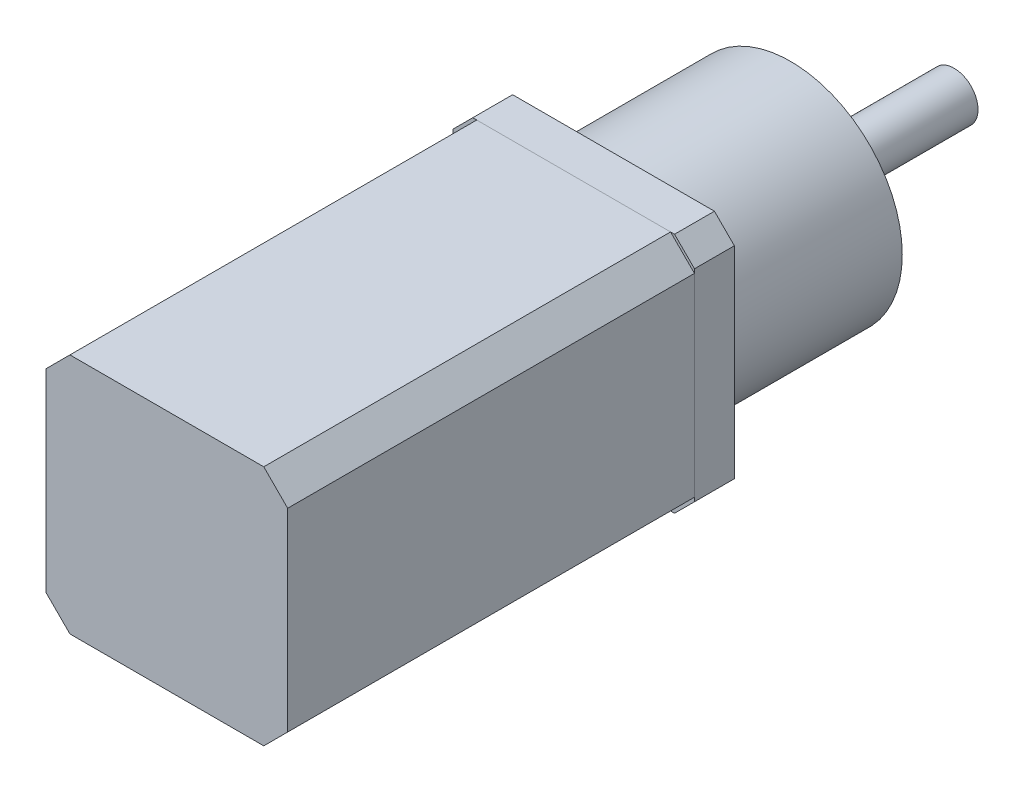
from build123d import *

# Parameters (mm, degrees)
SKETCH1_W           = 30.3
SKETCH1_H           = 30.3
BOSS_EXTRUDE1_DEPTH = 51
SKETCH4_W           = 30.3
SKETCH4_H           = 30.3
BOSS_EXTRUDE4_DEPTH = 5
SKETCH5_R           = 14
BOSS_EXTRUDE5_DEPTH = 22.2
SKETCH6_R           = 9
BOSS_EXTRUDE6_DEPTH = 2
SKETCH7_R           = 3
BOSS_EXTRUDE7_DEPTH = 18.5
SKETCH8_R           = 4.32234312
BOSS_EXTRUDE8_DEPTH = 0.4
CHAMFER1_SIZE       = 3
CHAMFER2_SIZE       = 2.5


with BuildPart() as part:
    # Sketch1 → Boss-Extrude1 (new body)
    with BuildSketch(Plane.XY):
        Rectangle(SKETCH1_W, SKETCH1_H)
    extrude(amount=BOSS_EXTRUDE1_DEPTH)

    # Chamfer1
    chamfer1_edges = [part.edges().sort_by_distance(p)[0] for p in [
        (15.15, -15.15, 25.5),
        (-15.15, -15.15, 25.5),
        (-15.15, 15.15, 25.5),
        (15.15, 15.15, 25.5),
    ]]
    chamfer(chamfer1_edges, length=CHAMFER1_SIZE)


with BuildPart() as body_2:
    # Sketch4 → Boss-Extrude4 (new body)
    with BuildSketch(Plane(origin=(0, 0, 0), x_dir=(-1, 0, 0), z_dir=(0, 0, -1))):
        Rectangle(SKETCH4_W, SKETCH4_H)
    extrude(amount=BOSS_EXTRUDE4_DEPTH)

    # Sketch5 → Boss-Extrude5 (add)
    with BuildSketch(Plane(origin=(0, 0, -5), x_dir=(-1, 0, 0), z_dir=(0, 0, -1))):
        Circle(SKETCH5_R)
    extrude(amount=BOSS_EXTRUDE5_DEPTH)

    # Sketch6 → Boss-Extrude6 (add)
    with BuildSketch(Plane(origin=(0, 0, -27.2), x_dir=(-1, 0, 0), z_dir=(0, 0, -1))):
        Circle(SKETCH6_R)
    extrude(amount=BOSS_EXTRUDE6_DEPTH)

    # Sketch7 → Boss-Extrude7 (add)
    with BuildSketch(Plane(origin=(0, 0, -29.2), x_dir=(-1, 0, 0), z_dir=(0, 0, -1))):
        Circle(SKETCH7_R)
    extrude(amount=BOSS_EXTRUDE7_DEPTH)

    # Sketch8 → Boss-Extrude8 (add)
    with BuildSketch(Plane(origin=(0, 0, -29.2), x_dir=(-1, 0, 0), z_dir=(0, 0, -1))):
        Circle(SKETCH8_R)
    extrude(amount=BOSS_EXTRUDE8_DEPTH)

    # Chamfer2
    chamfer2_edges = [body_2.edges().sort_by_distance(p)[0] for p in [
        (-15.15, -15.15, -2.5),
        (15.15, -15.15, -2.5),
        (15.15, 15.15, -2.5),
        (-15.15, 15.15, -2.5),
    ]]
    chamfer(chamfer2_edges, length=CHAMFER2_SIZE)


solid = Compound([part.part, body_2.part])
